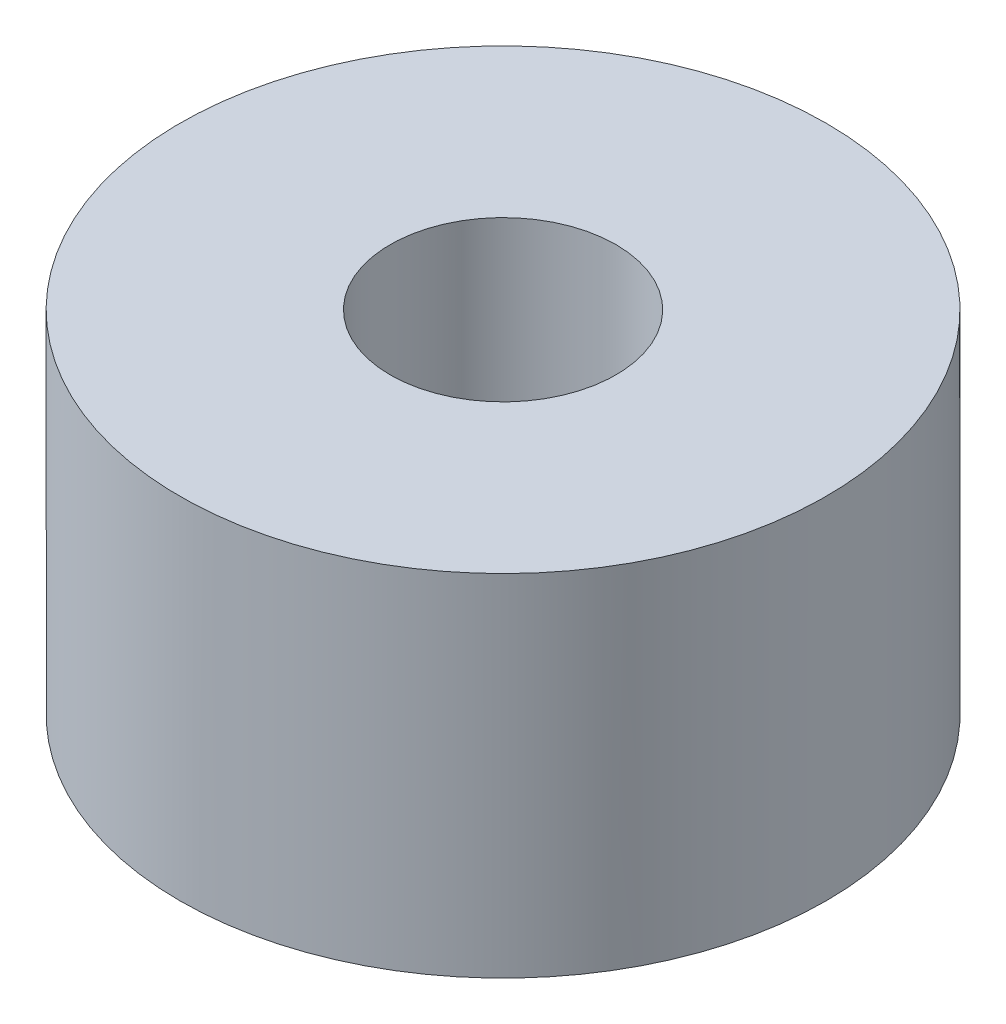
from build123d import *

# Parameters (mm, degrees)
SKETCH1_R           = 4.15
SKETCH1_R_2         = 1.45
BOSS_EXTRUDE1_DEPTH = 4.5


with BuildPart() as part:
    # Sketch1 → Boss-Extrude1 (new body)
    with BuildSketch(Plane(origin=(0, -39.451812113, 0), x_dir=(1, 0, 0), z_dir=(0, 1, 0))):
        with Locations((71.811675622, 2.147178548)):
            Circle(SKETCH1_R)
        with Locations((71.811675622, 2.147178548)):
            Circle(SKETCH1_R_2, mode=Mode.SUBTRACT)
    extrude(amount=BOSS_EXTRUDE1_DEPTH)


solid = part.part
